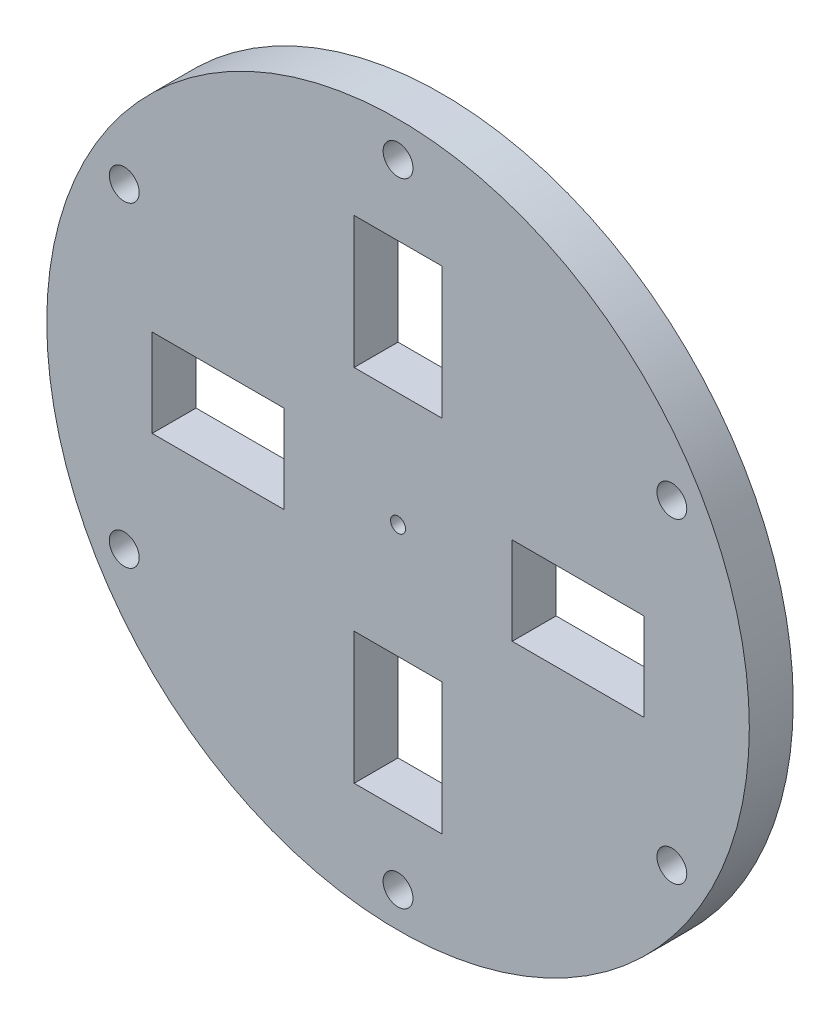
from build123d import *

# Parameters (mm, degrees)
SKETCH1_R           = 40
SKETCH1_R_2         = 0.75
BOSS_EXTRUDE1_DEPTH = 5
SKETCH4_W           = 10
SKETCH4_H           = 15
SKETCH4_W_2         = 15
SKETCH4_H_2         = 10
CUT_EXTRUDE3_DEPTH  = 6
SKETCH5_R           = 1.7
CUT_EXTRUDE4_DEPTH  = 6
SKETCH6_R           = 0.85
CUT_EXTRUDE5_DEPTH  = 6


with BuildPart() as part:
    # Sketch1 → Boss-Extrude1 (new body)
    with BuildSketch(Plane.XY):
        Circle(SKETCH1_R)
        Circle(SKETCH1_R_2, mode=Mode.SUBTRACT)
    extrude(amount=BOSS_EXTRUDE1_DEPTH)

    # Sketch4 → Cut-Extrude3 (cut, through all)
    with BuildSketch(Plane.XY.offset(5)):
        with Locations((0, 20.5)):
            Rectangle(SKETCH4_W, SKETCH4_H)
        with Locations((20.5, 0)):
            Rectangle(SKETCH4_W_2, SKETCH4_H_2)
        with Locations((0, -20.5)):
            Rectangle(SKETCH4_W, SKETCH4_H)
        with Locations((-20.5, 0)):
            Rectangle(SKETCH4_W_2, SKETCH4_H_2)
    extrude(amount=-CUT_EXTRUDE3_DEPTH, mode=Mode.SUBTRACT)

    # Sketch5 → Cut-Extrude4 (cut, through all)
    with BuildSketch(Plane.XY.offset(5)):
        with Locations((0, 36)):
            Circle(SKETCH5_R)
        with Locations((31.176914536, 18)):
            Circle(SKETCH5_R)
        with Locations((31.176914536, -18)):
            Circle(SKETCH5_R)
        with Locations((0, -36)):
            Circle(SKETCH5_R)
        with Locations((-31.176914536, -18)):
            Circle(SKETCH5_R)
        with Locations((-31.176914536, 18)):
            Circle(SKETCH5_R)
    extrude(amount=-CUT_EXTRUDE4_DEPTH, mode=Mode.SUBTRACT)

    # Sketch6 → Cut-Extrude5 (cut, through all)
    with BuildSketch(Plane.XY.offset(5)):
        Circle(SKETCH6_R)
    extrude(amount=-CUT_EXTRUDE5_DEPTH, mode=Mode.SUBTRACT)


solid = part.part
